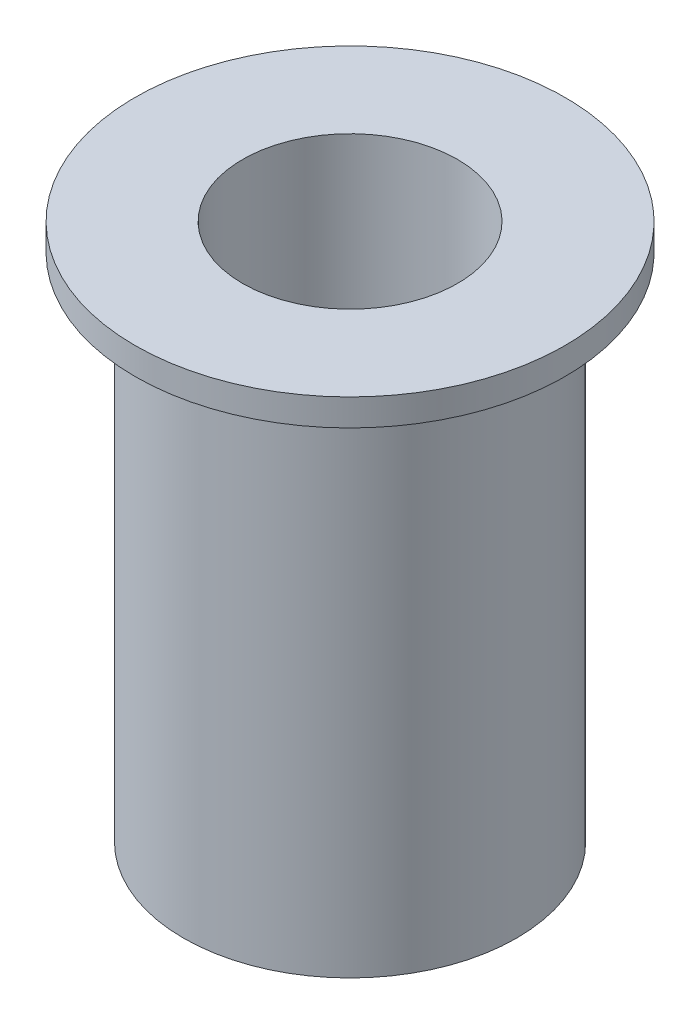
from build123d import *


with BuildPart() as part:
    # Sketch1 → Revolve1 (revolve)
    with BuildSketch(Plane.XY):
        Polygon((3.1, 0), (3.1, 9.5), (4, 9.5), (4, 10), (2, 10), (2, 0), align=None)
    revolve(axis=Axis((0, 10, 0), (0, -1, 0)))


solid = part.part
